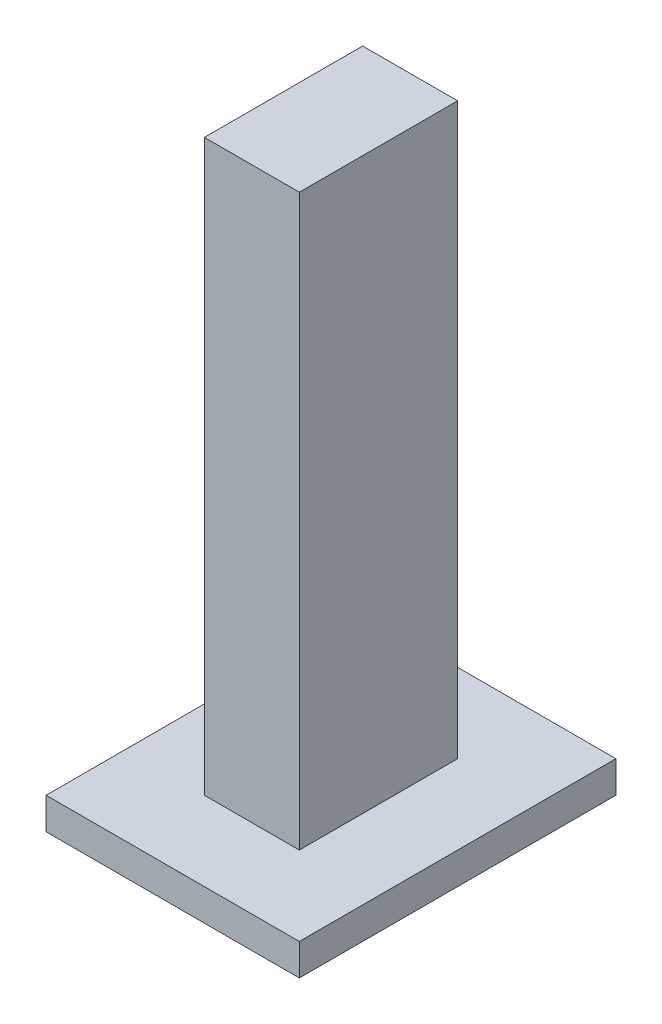
from build123d import *

# Parameters (mm, degrees)
SKIZZE1_W                       = 15
SKIZZE1_H                       = 90
AUFSATZ_LINEAR_AUSTRAGEN1_DEPTH = 25
SKIZZE2_W                       = 40
SKIZZE2_H                       = 50
AUFSATZ_LINEAR_AUSTRAGEN2_DEPTH = 5


with BuildPart() as part:
    # Skizze1 → Aufsatz-Linear austragen1 (new body)
    with BuildSketch(Plane.XY):
        with Locations((-7.5, 0)):
            Rectangle(SKIZZE1_W, SKIZZE1_H)
    extrude(amount=AUFSATZ_LINEAR_AUSTRAGEN1_DEPTH)

    # Skizze2 → Aufsatz-Linear austragen2 (add)
    with BuildSketch(Plane.XZ.offset(45)):
        with Locations((-7.5, 12.5)):
            Rectangle(SKIZZE2_W, SKIZZE2_H)
    extrude(amount=AUFSATZ_LINEAR_AUSTRAGEN2_DEPTH)


solid = part.part
